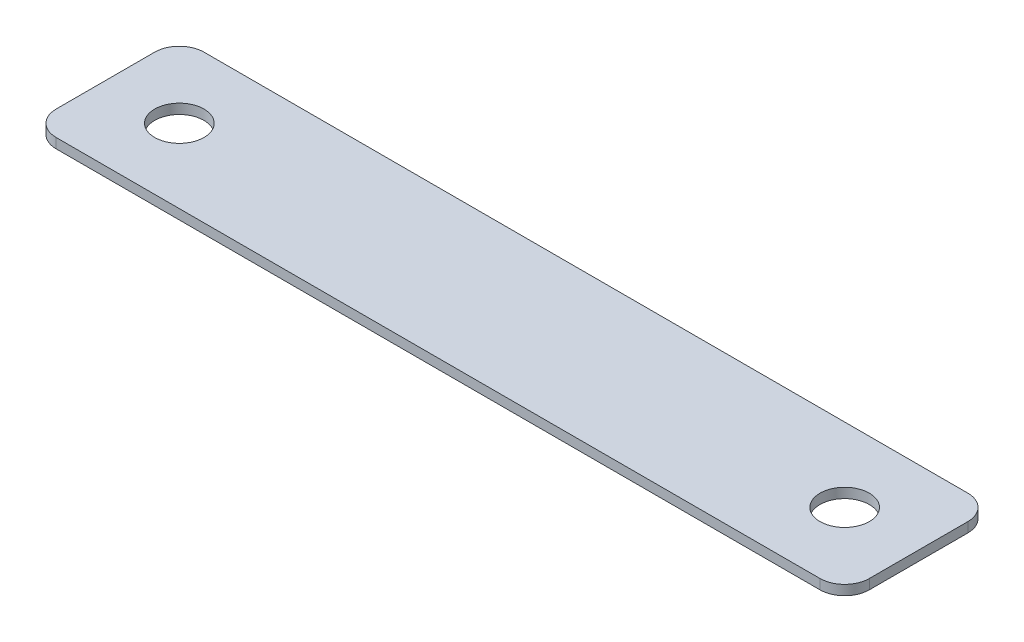
from build123d import *

# Parameters (mm, degrees)
SKETCH1_R           = 6.35
BOSS_EXTRUDE1_DEPTH = 2.54


with BuildPart() as part:
    # Sketch1 → Boss-Extrude1 (new body)
    with BuildSketch(Plane(origin=(0, 0, 0), x_dir=(1, 0, 0), z_dir=(0, 1, 0))):
        with BuildLine():
            Line((6.35, 0), (203.2, 0))
            ThreePointArc((203.2, 0), (207.690128061, 1.859871939), (209.55, 6.35))
            Line((209.55, 6.35), (209.55, 31.75))
            ThreePointArc((209.55, 31.75), (207.690128061, 36.240128061), (203.2, 38.1))
            Line((203.2, 38.1), (6.35, 38.1))
            ThreePointArc((6.35, 38.1), (1.859871939, 36.240128061), (0, 31.75))
            Line((0, 31.75), (0, 6.35))
            ThreePointArc((0, 6.35), (1.859871939, 1.859871939), (6.35, 0))
        make_face()
        with Locations((19.05, 19.05)):
            Circle(SKETCH1_R, mode=Mode.SUBTRACT)
        with Locations((190.5, 19.05)):
            Circle(SKETCH1_R, mode=Mode.SUBTRACT)
    extrude(amount=BOSS_EXTRUDE1_DEPTH)


solid = part.part
